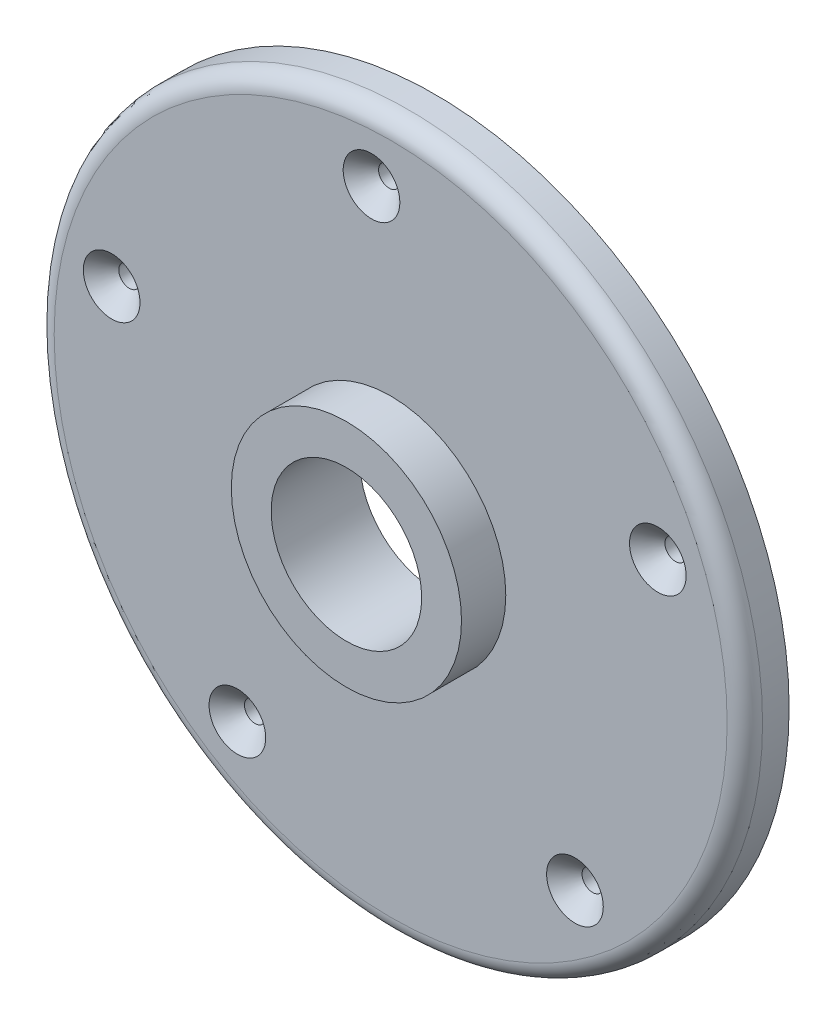
from build123d import *

# Parameters (mm, degrees)
SKETCH1_R           = 40
SKETCH1_R_2         = 8.5
BOSS_EXTRUDE1_DEPTH = 2.5
FILLET2_R           = 2
CIRPATTERN1_COUNT   = 5
SKETCH6_R           = 13
SKETCH6_R_2         = 8.5
BOSS_EXTRUDE2_DEPTH = 5


with BuildPart() as part:
    # Sketch1 → Boss-Extrude1 (new body, symmetric)
    with BuildSketch(Plane.XY):
        Circle(SKETCH1_R)
        Circle(SKETCH1_R_2, mode=Mode.SUBTRACT)
    extrude(amount=BOSS_EXTRUDE1_DEPTH, both=True)

    # Fillet2
    fillet2_edges = [part.edges().sort_by_distance(p)[0] for p in [
        (-40, 0, 2.5),
    ]]
    fillet(fillet2_edges, radius=FILLET2_R)

    # Sketch5 → CSK for M2 Flat Head Machine Screw1 (revolve, cut)
    with BuildSketch(Plane(origin=(-2.162785463, 32.427956443, 2.5), x_dir=(0, -1, 0), z_dir=(1, 0, 0))):
        Polygon((0, 0), (0, 5), (1.225, 5), (1.2, 4.975), (1.2, 2), (3.2, 0), align=None)
    csk_for_m2_flat_head_machine_screw1 = revolve(axis=Axis((-2.162785463, 32.427956443, 8.85), (0, 0, -1)), mode=Mode.SUBTRACT)

    # CirPattern1: CSK for M2 Flat Head Machine Screw1 ×5 about axis
    cirpattern1_axis = Axis((0, 0, 0), (0, 0, 1))
    for i in range(1, CIRPATTERN1_COUNT):
        add(csk_for_m2_flat_head_machine_screw1.rotate(cirpattern1_axis, i * 360 / CIRPATTERN1_COUNT), mode=Mode.SUBTRACT)

    # Sketch6 → Boss-Extrude2 (add)
    with BuildSketch(Plane.XY.offset(2.5)):
        Circle(SKETCH6_R)
        Circle(SKETCH6_R_2, mode=Mode.SUBTRACT)
    extrude(amount=BOSS_EXTRUDE2_DEPTH)


solid = part.part
